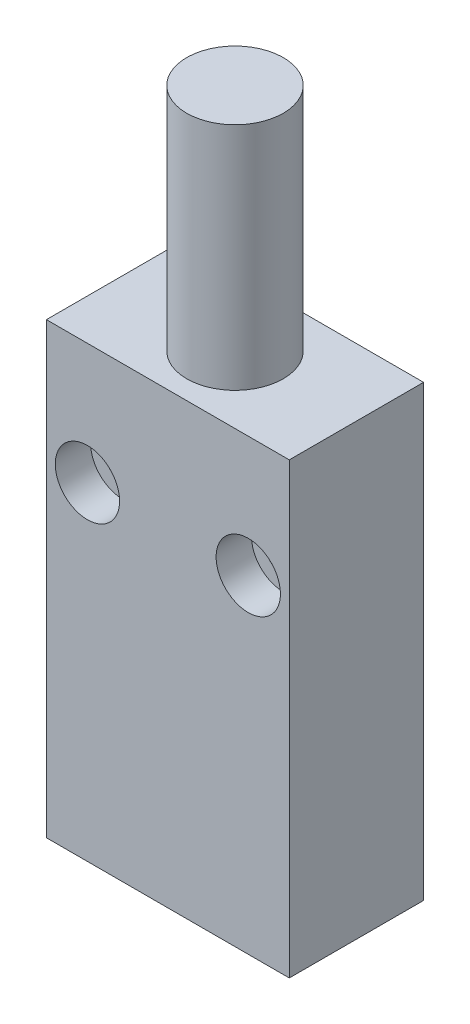
from build123d import *

# Parameters (mm, degrees)
SKETCH1_W                                           = 30.2
SKETCH1_H                                           = 55.8
BOSS_EXTRUDE1_DEPTH                                 = 8.35
CBORE_FOR_M4_HEX_SOCKET_HEAD_CAP_SCREW1_D           = 4.5
CBORE_FOR_M4_HEX_SOCKET_HEAD_CAP_SCREW1_CBORE_D     = 8
CBORE_FOR_M4_HEX_SOCKET_HEAD_CAP_SCREW1_CBORE_DEPTH = 4.4
BOSS_EXTRUDE2_START                                 = -15
SKETCH4_R                                           = 6
BOSS_EXTRUDE2_DEPTH                                 = 43.6


with BuildPart() as part:
    # Sketch1 → Boss-Extrude1 (new body, symmetric)
    with BuildSketch(Plane.XY):
        Rectangle(SKETCH1_W, SKETCH1_H)
    extrude(amount=BOSS_EXTRUDE1_DEPTH, both=True)

    # CBORE for M4 Hex Socket Head Cap Screw1 (through all)
    with Locations(Plane.XY.offset(8.35)):
        with Locations((-10, 12.9), (10, 12.9)):
            CounterBoreHole(CBORE_FOR_M4_HEX_SOCKET_HEAD_CAP_SCREW1_D / 2, CBORE_FOR_M4_HEX_SOCKET_HEAD_CAP_SCREW1_CBORE_D / 2, CBORE_FOR_M4_HEX_SOCKET_HEAD_CAP_SCREW1_CBORE_DEPTH)

    # Sketch4 → Boss-Extrude2 (add)
    with BuildSketch(Plane(origin=(0, 27.9, 0), x_dir=(1, 0, 0), z_dir=(0, 1, 0)).offset(BOSS_EXTRUDE2_START)):
        Circle(SKETCH4_R)
    extrude(amount=BOSS_EXTRUDE2_DEPTH)


solid = part.part
